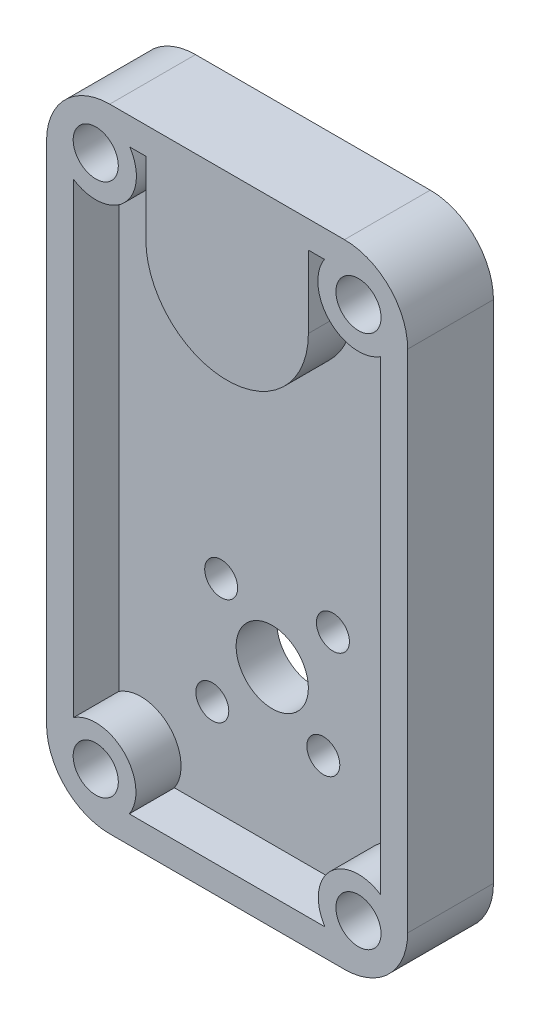
from build123d import *

# Parameters (mm, degrees)
SKETCH1_W           = 40
SKETCH1_H           = 70
SKETCH1_R           = 1.825
SKETCH1_R_2         = 4
BOSS_EXTRUDE1_DEPTH = 4.5
SKETCH3_W           = 40
SKETCH3_H           = 70
BOSS_EXTRUDE2_DEPTH = 5
SKETCH6_R           = 2.5
CUT_EXTRUDE3_DEPTH  = 7
SKETCH4_R           = 7
CUT_EXTRUDE1_DEPTH  = 7.5
FILLET1_R           = 7
TEXT_2804_DEPTH     = 1


with BuildPart() as part:
    # Sketch1 → Boss-Extrude1 (new body)
    with BuildSketch(Plane.XY):
        with Locations((20, 35)):
            Rectangle(SKETCH1_W, SKETCH1_H)
        with Locations((25.656854249, 14.343145751)):
            Circle(SKETCH1_R, mode=Mode.SUBTRACT)
        with Locations((14.343145751, 25.656854249)):
            Circle(SKETCH1_R, mode=Mode.SUBTRACT)
        with Locations((20, 20)):
            Circle(SKETCH1_R_2, mode=Mode.SUBTRACT)
        with Locations((26.717514421, 26.717514421)):
            Circle(SKETCH1_R, mode=Mode.SUBTRACT)
        with Locations((13.358757211, 13.358757211)):
            Circle(SKETCH1_R, mode=Mode.SUBTRACT)
    extrude(amount=BOSS_EXTRUDE1_DEPTH)

    # Sketch3 → Boss-Extrude2 (add)
    with BuildSketch(Plane.XY.offset(4.5)):
        with Locations((20, 35)):
            Rectangle(SKETCH3_W, SKETCH3_H)
        with BuildLine():
            Line((9.164835124, 3), (30.835164876, 3))
            ThreePointArc((30.835164876, 3), (31.403374824, 8.596625176), (37, 9.164835124))
            Line((37, 9.164835124), (37, 60.77541393))
            ThreePointArc((37, 60.77541393), (31.368019485, 61.368019485), (30.77541393, 67))
            Line((30.77541393, 67), (29, 67))
            Line((29, 67), (29, 59))
            ThreePointArc((29, 59), (20, 50), (11, 59))
            Line((11, 59), (11, 67))
            Line((11, 67), (9.22458607, 67))
            ThreePointArc((9.22458607, 67), (8.631980515, 61.368019485), (3, 60.77541393))
            Line((3, 60.77541393), (3, 9.164835124))
            ThreePointArc((3, 9.164835124), (8.596625176, 8.596625176), (9.164835124, 3))
        make_face(mode=Mode.SUBTRACT)
    extrude(amount=BOSS_EXTRUDE2_DEPTH)

    # Sketch6 → Cut-Extrude3 (cut)
    with BuildSketch(Plane.XY.offset(9.5)):
        with Locations((5.45, 64.55)):
            Circle(SKETCH6_R)
        with Locations((5.45, 5.45)):
            Circle(SKETCH6_R)
        with Locations((34.55, 5.45)):
            Circle(SKETCH6_R)
        with Locations((34.55, 64.55)):
            Circle(SKETCH6_R)
    extrude(amount=-CUT_EXTRUDE3_DEPTH, mode=Mode.SUBTRACT)

    # Sketch4 → Cut-Extrude1 (cut)
    with BuildSketch(Plane(origin=(0, 0, 0), x_dir=(-1, 0, 0), z_dir=(0, 0, -1))):
        with Locations((-20, 59)):
            Circle(SKETCH4_R)
    extrude(amount=-CUT_EXTRUDE1_DEPTH, mode=Mode.SUBTRACT)

    # Fillet1
    fillet1_edges = [part.edges().sort_by_distance(p)[0] for p in [
        (0, 70, 4.75),
        (40, 70, 4.75),
        (40, 0, 4.75),
        (0, 0, 4.75),
    ]]
    fillet(fillet1_edges, radius=FILLET1_R)

    # Sketch9 → Text-2804 (cut)
    with BuildSketch(Plane(origin=(0, 0, 0), x_dir=(-1, 0, 0), z_dir=(0, 0, -1))):
        with BuildLine():
            Line((-11.980426125, 44.596523498), (-10.914320356, 44.286427345))
            add(Edge.make_bspline(
                [(-10.914320356, 44.286427345), (-10.941121501, 44.212201398), (-10.993377806, 44.067477224), (-11.090992823, 43.863360404), (-11.198202606, 43.675175785), (-11.319635477, 43.504666634), (-11.451335999, 43.349843442), (-11.597197903, 43.213418702), (-11.753396357, 43.092191437), (-11.922094381, 42.990509858), (-12.098142142, 42.906636666), (-12.279978738, 42.840895291), (-12.466472117, 42.794846874), (-12.658355143, 42.77029452), (-12.854390813, 42.762290422), (-13.055534714, 42.77678538), (-13.261286477, 42.8084484), (-13.397775761, 42.844839195), (-13.467204971, 42.863350421)],
                knots=[0, 0, 0, 0, 0.000236617, 0.000461351, 0.000677817, 0.000885583, 0.001088434, 0.001286547, 0.001483677, 0.001680533, 0.001876225, 0.00206784, 0.002259655, 0.002451229, 0.002647275, 0.002847232, 0.003055307, 0.003270733, 0.003270733, 0.003270733, 0.003270733], degree=3))
            add(Edge.make_bspline(
                [(-13.467204971, 42.863350421), (-13.551282692, 42.890632494), (-13.715534034, 42.943929814), (-13.944579077, 43.055404246), (-14.149072169, 43.19130747), (-14.331226731, 43.34746937), (-14.485491351, 43.526929537), (-14.614473349, 43.724787633), (-14.715993262, 43.941620294), (-14.787672851, 44.173161712), (-14.832596499, 44.409991215), (-14.845666141, 44.64421054), (-14.830715423, 44.872319464), (-14.795061628, 45.017963224), (-14.777301125, 45.090513883)],
                knots=[0, 0, 0, 0, 0.00026495, 0.000517597, 0.000761279, 0.000999854, 0.001235038, 0.001468734, 0.00170639, 0.001950818, 0.0021941, 0.002427647, 0.002653036, 0.002876752, 0.002876752, 0.002876752, 0.002876752], degree=3))
            add(Edge.make_bspline(
                [(-14.777301125, 45.090513883), (-14.763794427, 45.133156964), (-14.736334784, 45.219852012), (-14.684867349, 45.348348493), (-14.621207088, 45.475468904), (-14.55116938, 45.603726442), (-14.467789297, 45.729425349), (-14.378729371, 45.857589017), (-14.276712372, 45.983353663), (-14.165629164, 46.110773523), (-14.040816295, 46.239582325), (-13.898570574, 46.368436085), (-13.740265279, 46.501209968), (-13.565691194, 46.6368378), (-13.371906844, 46.772030657), (-13.16291963, 46.912030694), (-12.935968893, 47.05312752), (-12.777902225, 47.146139538), (-12.696772279, 47.193879268)],
                knots=[0, 0, 0, 0, 0.000134169, 0.000272771, 0.00041468, 0.000560489, 0.000710845, 0.000866915, 0.001028532, 0.001196324, 0.001373969, 0.001566232, 0.001771831, 0.001993731, 0.002229164, 0.002480513, 0.002748315, 0.003030713, 0.003030713, 0.003030713, 0.003030713], degree=3))
            Line((-12.696772279, 47.193879268), (-11.855426125, 47.685465806))
            Line((-11.855426125, 47.685465806), (-13.902301125, 48.280417729))
            Line((-13.902301125, 48.280417729), (-13.607829971, 49.29243696))
            Line((-13.607829971, 49.29243696), (-9.62706074, 48.13618696))
            Line((-9.62706074, 48.13618696), (-9.779704971, 47.612148498))
            Line((-9.779704971, 47.612148498), (-12.08379151, 46.315273498))
            add(Edge.make_bspline(
                [(-12.08379151, 46.315273498), (-12.150862381, 46.277496275), (-12.280077296, 46.204716832), (-12.464670632, 46.094680163), (-12.633964003, 45.989783912), (-12.787028209, 45.887450556), (-12.923882704, 45.788918368), (-13.045990625, 45.695482436), (-13.151769739, 45.605466046), (-13.269703734, 45.494265722), (-13.392584927, 45.357218894), (-13.513926046, 45.192174314), (-13.608670789, 45.028843715), (-13.647916043, 44.91534193), (-13.666724202, 44.860946575)],
                knots=[0, 0, 0, 0, 0.000230926, 0.000444888, 0.000644657, 0.000828335, 0.000997119, 0.001150499, 0.001289471, 0.001413601, 0.00163659, 0.001840453, 0.002027706, 0.002200034, 0.002200034, 0.002200034, 0.002200034], degree=3))
            add(Edge.make_bspline(
                [(-13.666724202, 44.860946575), (-13.679855555, 44.807192639), (-13.705386356, 44.702680856), (-13.704335385, 44.542747893), (-13.672781872, 44.389330911), (-13.609525549, 44.245457588), (-13.520493515, 44.114170955), (-13.401129436, 44.008130344), (-13.262217189, 43.918860263), (-13.155759648, 43.883875256), (-13.100618433, 43.865754268)],
                knots=[0, 0, 0, 0, 0.000165473, 0.000321723, 0.000475179, 0.000632369, 0.000790407, 0.000946934, 0.001108355, 0.001281807, 0.001281807, 0.001281807, 0.001281807], degree=3))
            add(Edge.make_bspline(
                [(-13.100618433, 43.865754268), (-13.071483959, 43.858415198), (-13.014479284, 43.844055533), (-12.927951069, 43.831745064), (-12.842848872, 43.829145682), (-12.758728528, 43.836951587), (-12.675925399, 43.852005672), (-12.594512064, 43.877731533), (-12.515157851, 43.913149761), (-12.436614209, 43.956212849), (-12.361795848, 44.008730195), (-12.291194923, 44.069409801), (-12.226606555, 44.138372722), (-12.165761781, 44.214137914), (-12.112208254, 44.298969091), (-12.06253528, 44.390800912), (-12.018155298, 44.49054621), (-11.993183848, 44.560688393), (-11.980426125, 44.596523498)],
                knots=[0, 0, 0, 0, 9.0088e-05, 0.000176267, 0.000261637, 0.000344883, 0.000429275, 0.000513667, 0.000600313, 0.00068962, 0.000781981, 0.00087402, 0.000968392, 0.001065063, 0.001165083, 0.001268874, 0.001378097, 0.001492185, 0.001492185, 0.001492185, 0.001492185], degree=3))
        make_face()
        with BuildLine():
            Line((-16.801116274, 45.665601706), (-15.69414512, 45.564640168))
            add(Edge.make_bspline(
                [(-15.69414512, 45.564640168), (-15.706593734, 45.486692591), (-15.730907352, 45.334451744), (-15.786300812, 45.114744505), (-15.857743433, 44.909562388), (-15.942082798, 44.717567768), (-16.044483496, 44.541207625), (-16.159211561, 44.377662297), (-16.291969747, 44.230645634), (-16.43661818, 44.09694991), (-16.594087515, 43.98129753), (-16.759471876, 43.880881506), (-16.935213546, 43.802220762), (-17.117948363, 43.738877531), (-17.309887078, 43.695701166), (-17.509498235, 43.67094941), (-17.717932328, 43.663128319), (-17.858844208, 43.672716405), (-17.930923966, 43.677620937)],
                knots=[0, 0, 0, 0, 0.000236727, 0.000462356, 0.000678639, 0.000887932, 0.001090384, 0.001289486, 0.001486121, 0.001683478, 0.001879395, 0.002071301, 0.002262784, 0.002455871, 0.002650642, 0.002851752, 0.003058608, 0.003275225, 0.003275225, 0.003275225, 0.003275225], degree=3))
            add(Edge.make_bspline(
                [(-17.930923966, 43.677620937), (-18.018630228, 43.688362603), (-18.189952087, 43.709344937), (-18.435966324, 43.775260111), (-18.663859641, 43.867661751), (-18.871734317, 43.988438141), (-19.058298665, 44.135208821), (-19.223010293, 44.305505348), (-19.363284509, 44.500227485), (-19.478678564, 44.713743807), (-19.566299268, 44.938564614), (-19.626670107, 45.165732612), (-19.654992025, 45.392964374), (-19.647425104, 45.542971417), (-19.643664351, 45.617524783)],
                knots=[0, 0, 0, 0, 0.000264827, 0.000517302, 0.000761482, 0.001000614, 0.00123601, 0.001471467, 0.001708998, 0.001953701, 0.002197656, 0.002431166, 0.002657476, 0.002881085, 0.002881085, 0.002881085, 0.002881085], degree=3))
            add(Edge.make_bspline(
                [(-19.643664351, 45.617524783), (-19.638685383, 45.662089565), (-19.628583157, 45.752510619), (-19.601413564, 45.888130377), (-19.565790298, 46.025702093), (-19.517724362, 46.163937253), (-19.462874035, 46.304660978), (-19.397967865, 46.446991322), (-19.321140942, 46.589608745), (-19.237186973, 46.73666422), (-19.138739509, 46.886946819), (-19.024342881, 47.041451156), (-18.89388293, 47.201764074), (-18.746863571, 47.367512641), (-18.583586934, 47.538977471), (-18.403777003, 47.715456815), (-18.209456841, 47.898751643), (-18.071553409, 48.019415019), (-18.000635505, 48.081467091)],
                knots=[0, 0, 0, 0, 0.00013447, 0.000272838, 0.000414522, 0.000560475, 0.000711579, 0.000867551, 0.001029387, 0.001197403, 0.001375422, 0.001567977, 0.001773899, 0.001995288, 0.002232481, 0.002484054, 0.002751054, 0.003033728, 0.003033728, 0.003033728, 0.003033728], degree=3))
            Line((-18.000635505, 48.081467091), (-17.267462428, 48.72569786))
            Line((-17.267462428, 48.72569786), (-19.393664351, 48.919207475))
            Line((-19.393664351, 48.919207475), (-19.297510505, 49.969688245))
            Line((-19.297510505, 49.969688245), (-15.164097043, 49.594688245))
            Line((-15.164097043, 49.594688245), (-15.213375889, 49.051419014))
            Line((-15.213375889, 49.051419014), (-17.230202812, 47.336274783))
            add(Edge.make_bspline(
                [(-17.230202812, 47.336274783), (-17.289039333, 47.286585074), (-17.402712483, 47.190583719), (-17.561731148, 47.045261005), (-17.709338894, 46.910489036), (-17.84025033, 46.780784797), (-17.955728059, 46.657434478), (-18.058839094, 46.542993627), (-18.144961069, 46.433494134), (-18.239825518, 46.30140944), (-18.335272412, 46.143427133), (-18.420358595, 45.957077669), (-18.484149485, 45.779444739), (-18.500142898, 45.66043134), (-18.507847043, 45.603101706)],
                knots=[0, 0, 0, 0, 0.00023101, 0.000446315, 0.000646186, 0.000830613, 0.000998968, 0.001153082, 0.001292551, 0.001416623, 0.001640891, 0.001844712, 0.002030952, 0.002204045, 0.002204045, 0.002204045, 0.002204045], degree=3))
            add(Edge.make_bspline(
                [(-18.507847043, 45.603101706), (-18.510510016, 45.547714579), (-18.515685971, 45.440060007), (-18.485473581, 45.28277669), (-18.425855423, 45.138027168), (-18.335867332, 45.009197426), (-18.221926173, 44.89928304), (-18.08570275, 44.815426962), (-17.930589719, 44.75687032), (-17.819250271, 44.741888526), (-17.761452812, 44.734111322)],
                knots=[0, 0, 0, 0, 0.00016587, 0.000322397, 0.000475966, 0.000632331, 0.000790447, 0.000947536, 0.001109171, 0.001283653, 0.001283653, 0.001283653, 0.001283653], degree=3))
            add(Edge.make_bspline(
                [(-17.761452812, 44.734111322), (-17.731417368, 44.732328612), (-17.672526509, 44.728833232), (-17.585000364, 44.733581819), (-17.500859736, 44.748214004), (-17.419796359, 44.770987215), (-17.342190059, 44.802787104), (-17.266951365, 44.842546363), (-17.19512788, 44.892122954), (-17.126325585, 44.949728181), (-17.063300199, 45.015889734), (-17.004783813, 45.08803042), (-16.954467146, 45.168305186), (-16.90987355, 45.254618531), (-16.872717763, 45.348180361), (-16.841426642, 45.447726107), (-16.817375597, 45.55432788), (-16.806631556, 45.627856803), (-16.801116274, 45.665601706)],
                knots=[0, 0, 0, 0, 9.0216e-05, 0.000176888, 0.00026225, 0.000345954, 0.000428983, 0.0005134, 0.000600745, 0.00069031, 0.000782114, 0.000874466, 0.000968493, 0.00106579, 0.001165557, 0.001270096, 0.001378563, 0.001492973, 0.001492973, 0.001492973, 0.001492973], degree=3))
        make_face()
        with BuildLine():
            add(Edge.make_bspline(
                [(-22.429041628, 43.689408671), (-22.482284477, 43.684635604), (-22.586625895, 43.6752817), (-22.742091823, 43.67450932), (-22.892777705, 43.683582921), (-23.039247066, 43.704684691), (-23.180968083, 43.733888874), (-23.318226774, 43.775644629), (-23.450913265, 43.82686301), (-23.579198302, 43.888598232), (-23.702463737, 43.960468694), (-23.819036187, 44.045678638), (-23.931655291, 44.140372121), (-24.036652382, 44.248337873), (-24.138722139, 44.364916659), (-24.233238443, 44.494026183), (-24.322453076, 44.634312492), (-24.406786038, 44.786188422), (-24.486107792, 44.952212157), (-24.555764443, 45.135189107), (-24.620886078, 45.334096628), (-24.679408232, 45.549601119), (-24.732170767, 45.782195643), (-24.778786897, 46.03155184), (-24.818343208, 46.29782327), (-24.839059254, 46.481005072), (-24.849714705, 46.575225978)],
                knots=[0, 0, 0, 0, 0.000160307, 0.000314158, 0.000465905, 0.000612766, 0.000757741, 0.000899573, 0.001042647, 0.001184031, 0.001326264, 0.001470039, 0.001616703, 0.001767135, 0.001921361, 0.002081222, 0.002246599, 0.002419842, 0.002602099, 0.002798072, 0.00300674, 0.003229799, 0.003467722, 0.003722079, 0.003990649, 0.004275099, 0.004275099, 0.004275099, 0.004275099], degree=3))
            add(Edge.make_bspline(
                [(-24.849714705, 46.575225978), (-24.859240539, 46.67092096), (-24.877711347, 46.856475706), (-24.892935105, 47.127936848), (-24.899383912, 47.383691626), (-24.896029314, 47.624281031), (-24.883236495, 47.849321844), (-24.86042421, 48.059132419), (-24.829176304, 48.253750358), (-24.785026471, 48.433316451), (-24.732996564, 48.599523852), (-24.675426354, 48.754877042), (-24.611751812, 48.900682073), (-24.539814338, 49.035163887), (-24.462770627, 49.160940956), (-24.377373798, 49.274754615), (-24.285514814, 49.378631619), (-24.187733382, 49.473525007), (-24.081434766, 49.558024487), (-23.966637121, 49.632318466), (-23.844601241, 49.698858585), (-23.714540404, 49.756809533), (-23.575591206, 49.804574661), (-23.428582825, 49.844032764), (-23.273718261, 49.875832982), (-23.167140333, 49.888496817), (-23.112935859, 49.894937517)],
                knots=[0, 0, 0, 0, 0.000288474, 0.000559358, 0.000815438, 0.00105585, 0.001280998, 0.001491375, 0.001688773, 0.001871844, 0.002045575, 0.002211009, 0.002368681, 0.002522457, 0.002668207, 0.002810755, 0.002948699, 0.003083855, 0.003219006, 0.003355354, 0.003493581, 0.003635631, 0.003781975, 0.003933879, 0.004092045, 0.004255741, 0.004255741, 0.004255741, 0.004255741], degree=3))
            add(Edge.make_bspline(
                [(-23.112935859, 49.894937517), (-23.058488742, 49.899580704), (-22.951332126, 49.908718897), (-22.792705277, 49.911281736), (-22.639749731, 49.902661265), (-22.49222369, 49.88503565), (-22.350297458, 49.856240692), (-22.213911573, 49.81664909), (-22.083884889, 49.765781566), (-21.959063244, 49.705483778), (-21.839707823, 49.6341882), (-21.725167487, 49.552132004), (-21.61603823, 49.459494138), (-21.511562469, 49.356582203), (-21.413774152, 49.242027658), (-21.319116758, 49.117704745), (-21.230868341, 48.982063905), (-21.146998755, 48.834990476), (-21.068140407, 48.674585546), (-20.997702605, 48.496675472), (-20.932967856, 48.301591298), (-20.874575717, 48.088848279), (-20.821831778, 47.858650376), (-20.774961337, 47.610933083), (-20.735689927, 47.34541068), (-20.714949833, 47.162233149), (-20.704282013, 47.06801444)],
                knots=[0, 0, 0, 0, 0.000163903, 0.000322575, 0.000475451, 0.00062319, 0.00076792, 0.000909411, 0.001048689, 0.001186302, 0.001324821, 0.00146524, 0.001608516, 0.00175385, 0.001904685, 0.002059975, 0.002222324, 0.002389741, 0.002567666, 0.002758049, 0.002963293, 0.003184035, 0.003419615, 0.003671609, 0.003940179, 0.004224629, 0.004224629, 0.004224629, 0.004224629], degree=3))
            add(Edge.make_bspline(
                [(-20.704282013, 47.06801444), (-20.691758747, 46.936697374), (-20.667623593, 46.683619825), (-20.653739646, 46.315743401), (-20.655873589, 45.974253425), (-20.678621322, 45.658735751), (-20.717984342, 45.369083889), (-20.778406178, 45.106293207), (-20.853876982, 44.867926612), (-20.924884187, 44.72473361), (-20.959089705, 44.655754825)],
                knots=[0, 0, 0, 0, 0.000395665, 0.000762535, 0.0011039, 0.001419631, 0.001710973, 0.001979795, 0.002227989, 0.002458673, 0.002458673, 0.002458673, 0.002458673], degree=3))
            add(Edge.make_bspline(
                [(-20.959089705, 44.655754825), (-20.999542366, 44.586970142), (-21.078924492, 44.45199078), (-21.223479116, 44.271296095), (-21.382857111, 44.112879615), (-21.560343077, 43.979710177), (-21.753707264, 43.869618272), (-21.963791193, 43.783957598), (-22.190298246, 43.721917434), (-22.348175651, 43.700419878), (-22.429041628, 43.689408671)],
                knots=[0, 0, 0, 0, 0.000239137, 0.00046927, 0.000691947, 0.00091166, 0.001132895, 0.001357658, 0.001590626, 0.001835255, 0.001835255, 0.001835255, 0.001835255], degree=3))
        make_face()
        with BuildLine():
            add(Edge.make_bspline(
                [(-22.569666628, 44.75551444), (-22.523604982, 44.762707138), (-22.432595439, 44.776918618), (-22.303541229, 44.826476258), (-22.185338324, 44.897303128), (-22.096628219, 44.973543498), (-22.032743152, 45.046644781), (-21.98875962, 45.110728089), (-21.947338099, 45.181874672), (-21.911726258, 45.26140969), (-21.880517262, 45.348742699), (-21.853047403, 45.443920834), (-21.829069656, 45.54696622), (-21.809615604, 45.658899236), (-21.795885028, 45.780942398), (-21.784441353, 45.914363523), (-21.780423681, 46.060377066), (-21.780576557, 46.219081063), (-21.785010162, 46.39026826), (-21.797040178, 46.573689952), (-21.810457415, 46.76977705), (-21.824452667, 46.904589223), (-21.831685859, 46.97426444)],
                knots=[0, 0, 0, 0, 0.000139547, 0.000275721, 0.000411559, 0.000551313, 0.000624581, 0.000702271, 0.000784116, 0.000871254, 0.000963262, 0.001062156, 0.00116828, 0.001280516, 0.001402764, 0.001536616, 0.001682128, 0.001840782, 0.002012724, 0.002195736, 0.00239218, 0.00260231, 0.00260231, 0.00260231, 0.00260231], degree=3))
            add(Edge.make_bspline(
                [(-21.831685859, 46.97426444), (-21.841855722, 47.064090226), (-21.861377842, 47.236520252), (-21.899739413, 47.483146166), (-21.944134964, 47.707310582), (-21.993135816, 47.909305677), (-22.051596798, 48.0879233), (-22.112968181, 48.245510519), (-22.181942897, 48.380297019), (-22.257650678, 48.493191402), (-22.338341135, 48.587207528), (-22.422565941, 48.666449404), (-22.509214046, 48.733756288), (-22.600422647, 48.786400912), (-22.695720904, 48.823792381), (-22.794518625, 48.846641454), (-22.896453361, 48.85688013), (-22.965097925, 48.852626382), (-22.99995509, 48.850466363)],
                knots=[0, 0, 0, 0, 0.00027118, 0.000520558, 0.000748496, 0.000956633, 0.001143639, 0.001311926, 0.001463521, 0.001596864, 0.001718757, 0.001834391, 0.00194329, 0.002047199, 0.0021492, 0.002249198, 0.002350616, 0.002455246, 0.002455246, 0.002455246, 0.002455246], degree=3))
            add(Edge.make_bspline(
                [(-22.99995509, 48.850466363), (-23.032999528, 48.845778417), (-23.098082231, 48.836545269), (-23.191476176, 48.806897582), (-23.278604531, 48.766037773), (-23.359283663, 48.712649112), (-23.431156851, 48.645267623), (-23.498274542, 48.567531179), (-23.558231167, 48.477369458), (-23.59121719, 48.410956611), (-23.608128167, 48.376908671)],
                knots=[0, 0, 0, 0, 9.9984e-05, 0.000196923, 0.000292625, 0.000387964, 0.000485794, 0.000587219, 0.000695559, 0.000809533, 0.000809533, 0.000809533, 0.000809533], degree=3))
            add(Edge.make_bspline(
                [(-23.608128167, 48.376908671), (-23.627653308, 48.330420605), (-23.668577882, 48.232981912), (-23.710264216, 48.071586547), (-23.740650042, 47.891370957), (-23.762393126, 47.691922635), (-23.771352932, 47.472741328), (-23.768090066, 47.23412592), (-23.755015824, 46.975902456), (-23.738227742, 46.797528345), (-23.729522397, 46.705033671)],
                knots=[0, 0, 0, 0, 0.000151103, 0.000316712, 0.000498504, 0.000699193, 0.000918154, 0.001156147, 0.001414899, 0.001693581, 0.001693581, 0.001693581, 0.001693581], degree=3))
            add(Edge.make_bspline(
                [(-23.729522397, 46.705033671), (-23.719009252, 46.611990469), (-23.698799165, 46.433127612), (-23.658454928, 46.177137623), (-23.615587827, 45.943662195), (-23.563516046, 45.734495635), (-23.507827291, 45.548252672), (-23.445625349, 45.385303694), (-23.378121195, 45.244884107), (-23.302718727, 45.127487106), (-23.221595104, 45.030240512), (-23.139429468, 44.946904191), (-23.053068824, 44.877908432), (-22.962307846, 44.825268299), (-22.869016034, 44.784488221), (-22.772202457, 44.758891123), (-22.671545278, 44.74921867), (-22.604114966, 44.753385644), (-22.569666628, 44.75551444)],
                knots=[0, 0, 0, 0, 0.00028087, 0.000539934, 0.00077731, 0.000992736, 0.00118626, 0.001360141, 0.001515487, 0.001652843, 0.001777496, 0.00189478, 0.002003466, 0.002107978, 0.002208668, 0.002308079, 0.002407105, 0.002510533, 0.002510533, 0.002510533, 0.002510533], degree=3))
        make_face(mode=Mode.SUBTRACT)
        with BuildLine():
            add(Edge.make_bspline(
                [(-28.911637668, 45.183441782), (-28.986978512, 45.206989167), (-29.135460872, 45.253396549), (-29.342148511, 45.35874709), (-29.534357823, 45.483535658), (-29.706949891, 45.63442474), (-29.859599647, 45.804783705), (-29.989341617, 45.992845947), (-30.09532239, 46.1967709), (-30.145015132, 46.342162383), (-30.17005113, 46.415412936)],
                knots=[0, 0, 0, 0, 0.000236422, 0.000465942, 0.000693293, 0.000922482, 0.001151457, 0.001377834, 0.001606294, 0.001838268, 0.001838268, 0.001838268, 0.001838268], degree=3))
            add(Edge.make_bspline(
                [(-30.17005113, 46.415412936), (-30.191646346, 46.497092063), (-30.234265831, 46.658290842), (-30.256657499, 46.906957824), (-30.249583632, 47.154857918), (-30.204687026, 47.39933365), (-30.133404274, 47.635360638), (-30.029007861, 47.854526963), (-29.896422628, 48.05409779), (-29.76277675, 48.203776619), (-29.639680637, 48.31144048), (-29.538710127, 48.390175593), (-29.427822685, 48.46299643), (-29.308397873, 48.531981497), (-29.179142925, 48.595304701), (-29.041293436, 48.655354192), (-28.893956093, 48.710780749), (-28.791992394, 48.743569302), (-28.739762668, 48.760364859)],
                knots=[0, 0, 0, 0, 0.000253058, 0.000499426, 0.000745964, 0.000994945, 0.001242815, 0.001483671, 0.001720352, 0.001959511, 0.002082982, 0.00221064, 0.002343316, 0.002480619, 0.002624137, 0.002774857, 0.002931569, 0.003096145, 0.003096145, 0.003096145, 0.003096145], degree=3))
            add(Edge.make_bspline(
                [(-28.739762668, 48.760364859), (-28.683827769, 48.776967046), (-28.574593874, 48.809389052), (-28.412290691, 48.847149196), (-28.257297035, 48.877912614), (-28.109228466, 48.898587064), (-27.967914874, 48.909430005), (-27.833475593, 48.911940698), (-27.705636632, 48.906677761), (-27.54569783, 48.885281292), (-27.353818334, 48.840055962), (-27.136651208, 48.748994948), (-26.931344426, 48.628020677), (-26.742280298, 48.474362223), (-26.570027632, 48.295735345), (-26.425895114, 48.089590651), (-26.303512403, 47.863350679), (-26.248570197, 47.698870343), (-26.220531899, 47.614932166)],
                knots=[0, 0, 0, 0, 0.000175003, 0.000341758, 0.000499691, 0.000648933, 0.000789974, 0.00092461, 0.001052156, 0.00117336, 0.001408322, 0.001641127, 0.001877148, 0.002120794, 0.002369883, 0.002619006, 0.00287332, 0.003138357, 0.003138357, 0.003138357, 0.003138357], degree=3))
            add(Edge.make_bspline(
                [(-26.220531899, 47.614932166), (-26.200762946, 47.541191888), (-26.161740295, 47.395633282), (-26.134060697, 47.173419819), (-26.135789271, 46.953429058), (-26.162942416, 46.73603431), (-26.219602325, 46.521628597), (-26.301813384, 46.30956822), (-26.413233502, 46.100683441), (-26.505188544, 45.968604451), (-26.552262668, 45.900989859)],
                knots=[0, 0, 0, 0, 0.000228839, 0.000451714, 0.000669266, 0.000887371, 0.001107178, 0.001332836, 0.001568342, 0.001815357, 0.001815357, 0.001815357, 0.001815357], degree=3))
            add(Edge.make_bspline(
                [(-26.552262668, 45.900989859), (-26.49844043, 45.869801109), (-26.393421633, 45.808945129), (-26.247323969, 45.70447876), (-26.116881875, 45.590242175), (-25.998828419, 45.468412857), (-25.896310853, 45.33715037), (-25.809334881, 45.196350409), (-25.73605924, 45.047270724), (-25.700928099, 44.941917746), (-25.683272284, 44.888970628)],
                knots=[0, 0, 0, 0, 0.000186546, 0.000363992, 0.000537777, 0.000706089, 0.000872224, 0.00103632, 0.001201889, 0.001369168, 0.001369168, 0.001369168, 0.001369168], degree=3))
            add(Edge.make_bspline(
                [(-25.683272284, 44.888970628), (-25.66358667, 44.815265388), (-25.624854866, 44.670248992), (-25.602794615, 44.447515203), (-25.609703171, 44.227209986), (-25.647024611, 44.010783471), (-25.713360756, 43.802713793), (-25.80633455, 43.605411967), (-25.929201379, 43.422819297), (-26.078742634, 43.255803737), (-26.253179547, 43.105725038), (-26.451240488, 42.976108615), (-26.672263255, 42.866135577), (-26.831158128, 42.812947232), (-26.912839591, 42.785605243)],
                knots=[0, 0, 0, 0, 0.000228558, 0.000449692, 0.000668561, 0.000888093, 0.00110628, 0.001321867, 0.001540214, 0.001764098, 0.001992501, 0.002228519, 0.002472554, 0.00273071, 0.00273071, 0.00273071, 0.00273071], degree=3))
            add(Edge.make_bspline(
                [(-26.912839591, 42.785605243), (-26.994160347, 42.763722109), (-27.153183048, 42.720929649), (-27.393445101, 42.689295659), (-27.626863042, 42.68950209), (-27.852244992, 42.717447456), (-28.067040122, 42.776631811), (-28.269084927, 42.864436845), (-28.457961249, 42.97919908), (-28.630126237, 43.121322304), (-28.78338567, 43.283621628), (-28.912967527, 43.463597075), (-29.020273897, 43.657860743), (-29.067923956, 43.797964969), (-29.09192613, 43.868537936)],
                knots=[0, 0, 0, 0, 0.00025245, 0.000493665, 0.000724434, 0.000951038, 0.001172938, 0.001390416, 0.001609948, 0.001833712, 0.002058185, 0.00227769, 0.002497645, 0.002720896, 0.002720896, 0.002720896, 0.002720896], degree=3))
            add(Edge.make_bspline(
                [(-29.09192613, 43.868537936), (-29.10594665, 43.919163459), (-29.133592644, 44.018988063), (-29.153802665, 44.171219815), (-29.162311488, 44.32169475), (-29.152099269, 44.473755301), (-29.123500254, 44.633041889), (-29.072380291, 44.803810902), (-29.002966281, 44.99055132), (-28.943108764, 45.116973301), (-28.911637668, 45.183441782)],
                knots=[0, 0, 0, 0, 0.000157415, 0.000310395, 0.000459608, 0.000608956, 0.000766449, 0.000944094, 0.001143008, 0.001363537, 0.001363537, 0.001363537, 0.001363537], degree=3))
        make_face()
        with BuildLine():
            add(Edge.make_bspline(
                [(-27.195291514, 43.840893705), (-27.153271138, 43.856108303), (-27.071642976, 43.885663956), (-26.963873638, 43.956158294), (-26.874017658, 44.043932386), (-26.805884467, 44.149385029), (-26.758266475, 44.266311536), (-26.736378071, 44.392066264), (-26.741658212, 44.523741378), (-26.763387624, 44.610008564), (-26.774618438, 44.654595628)],
                knots=[0, 0, 0, 0, 0.000133695, 0.000259713, 0.00038295, 0.000507962, 0.000633619, 0.000759293, 0.000887988, 0.00102566, 0.00102566, 0.00102566, 0.00102566], degree=3))
            add(Edge.make_bspline(
                [(-26.774618438, 44.654595628), (-26.790210749, 44.698205274), (-26.82039413, 44.782624219), (-26.892498857, 44.895589067), (-26.984949889, 44.988954823), (-27.094656271, 45.061694855), (-27.214613973, 45.113870384), (-27.341246958, 45.141239898), (-27.472699479, 45.140248513), (-27.557766533, 45.118772204), (-27.601541514, 45.107720628)],
                knots=[0, 0, 0, 0, 0.000138602, 0.000268304, 0.00039834, 0.000530015, 0.000660848, 0.000788614, 0.000916023, 0.001051094, 0.001051094, 0.001051094, 0.001051094], degree=3))
            add(Edge.make_bspline(
                [(-27.601541514, 45.107720628), (-27.644881772, 45.092738104), (-27.729128578, 45.063614379), (-27.838836372, 44.98979909), (-27.931651539, 44.900107316), (-28.000562021, 44.790899617), (-28.048803888, 44.669933096), (-28.068316066, 44.539167991), (-28.06420417, 44.401461821), (-28.040514504, 44.310935869), (-28.028224207, 44.263970628)],
                knots=[0, 0, 0, 0, 0.00013704, 0.000266385, 0.000393021, 0.000521711, 0.000650721, 0.00078094, 0.000915641, 0.00106087, 0.00106087, 0.00106087, 0.00106087], degree=3))
            add(Edge.make_bspline(
                [(-28.028224207, 44.263970628), (-28.013130813, 44.22071081), (-27.983863718, 44.136827142), (-27.912400899, 44.027115774), (-27.823450202, 43.93654633), (-27.717620819, 43.866666474), (-27.597704643, 43.820923413), (-27.468567451, 43.800565933), (-27.331936979, 43.804894139), (-27.241847705, 43.828628368), (-27.195291514, 43.840893705)],
                knots=[0, 0, 0, 0, 0.00013704, 0.00026573, 0.000388967, 0.000515643, 0.000643098, 0.000770943, 0.000905644, 0.0010497, 0.0010497, 0.0010497, 0.0010497], degree=3))
        make_face(mode=Mode.SUBTRACT)
        with BuildLine():
            add(Edge.make_bspline(
                [(-27.930868438, 46.111326397), (-27.868924093, 46.132643497), (-27.748142386, 46.174208482), (-27.587669501, 46.274516835), (-27.449827191, 46.397076063), (-27.341739992, 46.543987134), (-27.262191673, 46.702473644), (-27.218265204, 46.867679794), (-27.211675988, 47.035277234), (-27.238329323, 47.142529934), (-27.251781899, 47.196662936)],
                knots=[0, 0, 0, 0, 0.000195972, 0.000382115, 0.000563383, 0.000746316, 0.00092585, 0.001092311, 0.001255843, 0.001422495, 0.001422495, 0.001422495, 0.001422495], degree=3))
            add(Edge.make_bspline(
                [(-27.251781899, 47.196662936), (-27.261361585, 47.224465926), (-27.280285964, 47.279389888), (-27.315775963, 47.357753101), (-27.360250832, 47.428974777), (-27.408995534, 47.49634084), (-27.467793314, 47.555699684), (-27.530897213, 47.612051989), (-27.603029537, 47.659428463), (-27.679268806, 47.703019802), (-27.76099311, 47.73892103), (-27.846239322, 47.766906666), (-27.934633697, 47.784520437), (-28.025153909, 47.794670302), (-28.11855674, 47.793960029), (-28.214738449, 47.785861194), (-28.313596512, 47.76750972), (-28.37931163, 47.749248878), (-28.412839591, 47.739932166)],
                knots=[0, 0, 0, 0, 8.8208e-05, 0.000174253, 0.000257325, 0.000339777, 0.000423084, 0.000507433, 0.000593107, 0.000681364, 0.000770696, 0.000860398, 0.000949972, 0.001040627, 0.001133175, 0.001229697, 0.00132989, 0.001434256, 0.001434256, 0.001434256, 0.001434256], degree=3))
            add(Edge.make_bspline(
                [(-28.412839591, 47.739932166), (-28.446288577, 47.729261649), (-28.511727031, 47.708386213), (-28.604611878, 47.668461617), (-28.689994002, 47.622614392), (-28.768432544, 47.57253401), (-28.839048411, 47.516297664), (-28.902700282, 47.455539132), (-28.958701872, 47.388591169), (-29.006152083, 47.316983738), (-29.046190539, 47.24218494), (-29.077600793, 47.164828665), (-29.100473624, 47.085936894), (-29.114321909, 47.004870912), (-29.116879111, 46.922610787), (-29.113937091, 46.838453348), (-29.100569875, 46.75253327), (-29.084520931, 46.695715345), (-29.07630113, 46.666614859)],
                knots=[0, 0, 0, 0, 0.000105283, 0.000205973, 0.000302763, 0.000395778, 0.000484753, 0.000573157, 0.000659336, 0.000746008, 0.000830426, 0.000913454, 0.000996003, 0.001076424, 0.001159435, 0.001242446, 0.001328801, 0.001419464, 0.001419464, 0.001419464, 0.001419464], degree=3))
            add(Edge.make_bspline(
                [(-29.07630113, 46.666614859), (-29.066973964, 46.637893338), (-29.048723452, 46.5816938), (-29.009978846, 46.503162506), (-28.967505539, 46.428762371), (-28.915074627, 46.361922552), (-28.85767749, 46.300152705), (-28.792534024, 46.245185501), (-28.720656968, 46.196398999), (-28.617106974, 46.138862749), (-28.477078884, 46.086097003), (-28.299350302, 46.05906282), (-28.114246382, 46.064115414), (-27.993363321, 46.095236977), (-27.930868438, 46.111326397)],
                knots=[0, 0, 0, 0, 9.0472e-05, 0.000177027, 0.00026216, 0.000347022, 0.000431199, 0.000514765, 0.00060211, 0.000691417, 0.000869792, 0.001047437, 0.001227825, 0.001420902, 0.001420902, 0.001420902, 0.001420902], degree=3))
        make_face(mode=Mode.SUBTRACT)
    extrude(amount=-TEXT_2804_DEPTH, mode=Mode.SUBTRACT)


solid = part.part
